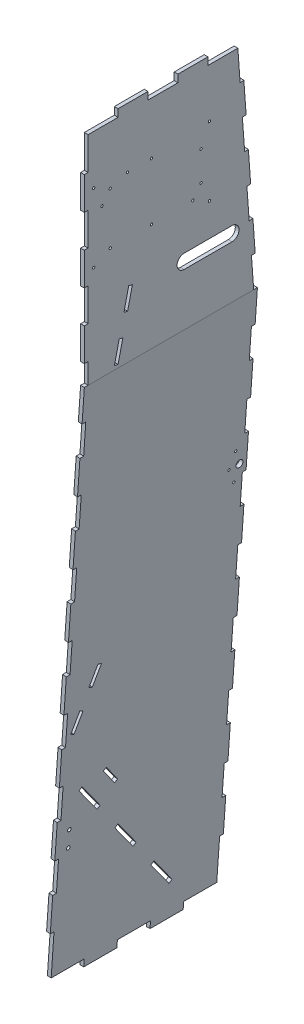
from build123d import *

# Parameters (mm, degrees)
BOSS_EXTRUDE1_DEPTH = 469.9
SKETCH2_W           = 10.16
SKETCH2_H           = 83.810703233
SKETCH2_H_2         = 111.159792755
SKETCH2_H_3         = 83.757510526
SKETCH2_H_4         = 83.784106879
SKETCH2_H_5         = 83.730914172
SKETCH2_H_6         = 83.704317819
SKETCH2_H_7         = 83.677721465
SKETCH2_H_8         = 83.651125112
SKETCH2_H_9         = 22.104476438
CUT_EXTRUDE1_DEPTH  = 10.16
SKETCH3_W           = 10.16
SKETCH3_H           = 55.879999965
SKETCH3_H_2         = 88.9
SKETCH3_H_3         = 109.22
CUT_EXTRUDE2_DEPTH  = 12.7
SKETCH4_W           = 81.316938584
SKETCH4_H           = 20.32
SKETCH4_W_2         = 81.316938585
CUT_EXTRUDE3_DEPTH  = 12.7
SKETCH5_W           = 89.916
SKETCH5_H           = 20.32
CUT_EXTRUDE4_DEPTH  = 12.7
CUT_EXTRUDE5_DEPTH  = 137.414
SKETCH8_R           = 9.525
CUT_EXTRUDE7_DEPTH  = 102.618210735
SKETCH13_R          = 3.175
CUT_EXTRUDE8_DEPTH  = 11.166490401
CUT_EXTRUDE9_DEPTH  = 11.166490401
SKETCH20_R          = 4.7625
CUT_EXTRUDE10_DEPTH = 112.516033618
SKETCH23_R          = 3.175
CUT_EXTRUDE11_DEPTH = 112.516033618


with BuildPart() as part:
    # Sketch1 → Boss-Extrude1 (new body)
    with BuildSketch(Plane.XY):
        Polygon((-215.881789204, 2052.32), (-215.881789204, 1463.040000035), (-316.088635901, 20.32), (-317.499999939, 0), (-307.333509538, 0), (-205.715298803, 1463.040000035), (-205.715298803, 2072.64), (-215.881789204, 2072.64), align=None)
    extrude(amount=-BOSS_EXTRUDE1_DEPTH)

    # Sketch2 → Cut-Extrude1 (cut)
    with BuildSketch(Plane(origin=(-315.975651309, 21.946686571, 0), x_dir=(0, 0, 1), z_dir=(-0.997596563, 0.069289956, 0))):
        with Locations((-5.08, 247.132760087)):
            Rectangle(SKETCH2_W, SKETCH2_H)
        with Locations((-5.08, 55.684811679)):
            Rectangle(SKETCH2_W, SKETCH2_H_2)
        with Locations((-5.08, 602.706163733)):
            Rectangle(SKETCH2_W, SKETCH2_H_3)
        with Locations((-5.08, 424.91946191)):
            Rectangle(SKETCH2_W, SKETCH2_H_4)
        with Locations((-5.08, 780.492865556)):
            Rectangle(SKETCH2_W, SKETCH2_H_5)
        with Locations((-5.08, 958.27956738)):
            Rectangle(SKETCH2_W, SKETCH2_H_6)
        with Locations((-5.08, 1136.066269203)):
            Rectangle(SKETCH2_W, SKETCH2_H_7)
        with Locations((-5.08, 1313.852971026)):
            Rectangle(SKETCH2_W, SKETCH2_H_8)
        with Locations((-5.08, -10.947322918)):
            Rectangle(SKETCH2_W, SKETCH2_H_9)
        with Locations((-464.82, -10.947322918)):
            Rectangle(SKETCH2_W, SKETCH2_H_9)
        with Locations((-464.82, 55.684811679)):
            Rectangle(SKETCH2_W, SKETCH2_H_2)
        with Locations((-464.82, 247.132760087)):
            Rectangle(SKETCH2_W, SKETCH2_H)
        with Locations((-464.82, 424.91946191)):
            Rectangle(SKETCH2_W, SKETCH2_H_4)
        with Locations((-464.82, 602.706163733)):
            Rectangle(SKETCH2_W, SKETCH2_H_3)
        with Locations((-464.82, 780.492865556)):
            Rectangle(SKETCH2_W, SKETCH2_H_5)
        with Locations((-464.82, 958.27956738)):
            Rectangle(SKETCH2_W, SKETCH2_H_6)
        with Locations((-464.82, 1136.066269203)):
            Rectangle(SKETCH2_W, SKETCH2_H_7)
        with Locations((-464.82, 1313.852971026)):
            Rectangle(SKETCH2_W, SKETCH2_H_8)
    extrude(amount=-CUT_EXTRUDE1_DEPTH, mode=Mode.SUBTRACT)

    # Sketch3 → Cut-Extrude2 (cut)
    with BuildSketch(Plane.ZY.offset(215.881789204)):
        with Locations((-5.08, 1490.980000018)):
            Rectangle(SKETCH3_W, SKETCH3_H)
        with Locations((-5.08, 1652.27)):
            Rectangle(SKETCH3_W, SKETCH3_H_2)
        Polygon((-469.9, 1463.040000035), (-459.713026258, 1463.040000035), (-453.620872406, 1546.589538567), (-463.753970086, 1547.328410273), (-457.607940173, 1631.616820512), (-447.474842492, 1630.877948806), (-441.328812579, 1715.166359045), (-451.461910259, 1715.905230751), (-445.315880346, 1800.19364099), (-435.182782665, 1799.454769284), (-429.036752752, 1883.743179522), (-439.169850432, 1884.482051228), (-433.023820518, 1968.770461467), (-422.890722838, 1968.031589761), (-415.263026258, 2072.64), (-469.9, 2072.64), align=None)
        with Locations((-5.08, 1830.07)):
            Rectangle(SKETCH3_W, SKETCH3_H_2)
        with Locations((-5.08, 2018.03)):
            Rectangle(SKETCH3_W, SKETCH3_H_3)
    extrude(amount=-CUT_EXTRUDE2_DEPTH, mode=Mode.SUBTRACT)

    # Sketch4 → Cut-Extrude3 (cut)
    with BuildSketch(Plane.ZY.offset(215.881789204)):
        with Locations((-376.086223632, 2062.48)):
            Rectangle(SKETCH4_W, SKETCH4_H)
        with Locations((-213.452346463, 2062.48)):
            Rectangle(SKETCH4_W_2, SKETCH4_H)
        with Locations((-50.818469292, 2062.48)):
            Rectangle(SKETCH4_W_2, SKETCH4_H)
    extrude(amount=-CUT_EXTRUDE3_DEPTH, mode=Mode.SUBTRACT)

    # Sketch5 → Cut-Extrude4 (cut)
    with BuildSketch(Plane(origin=(-315.975651309, 21.946686571, 0), x_dir=(0, 0, 1), z_dir=(-0.997596563, 0.069289956, 0))):
        with Locations((-414.782, -11.839561137)):
            Rectangle(SKETCH5_W, SKETCH5_H)
        with Locations((-234.95, -11.839561137)):
            Rectangle(SKETCH5_W, SKETCH5_H)
        with Locations((-55.118, -11.839561137)):
            Rectangle(SKETCH5_W, SKETCH5_H)
    extrude(amount=-CUT_EXTRUDE4_DEPTH, mode=Mode.SUBTRACT)

    # Sketch6 → Cut-Extrude5 (cut)
    with BuildSketch(Plane(origin=(-315.975651309, 21.946686571, 0), x_dir=(0, 0, 1), z_dir=(-0.997596563, 0.069289956, 0))):
        Polygon((-87.26775037, 725.157981502), (-65.68812669, 678.917255627), (-74.89887104, 674.61878511), (-96.478494721, 720.859510985), align=None)
        Polygon((-53.31924736, 628.378059234), (-44.10850301, 632.676529752), (-22.52887933, 586.435803877), (-31.73962368, 582.137333359), align=None)
        Polygon((-117.688081031, 364.457321541), (-109.500847052, 358.426570287), (-55.568463259, 431.644155721), (-63.755697238, 437.674906975), align=None)
        Polygon((-225.552848619, 218.022150673), (-217.372552167, 211.996509631), (-163.440168374, 285.214095065), (-171.620464825, 291.239736107), align=None)
        Polygon((-333.417616206, 71.586979805), (-325.230382227, 65.556228551), (-271.297998434, 138.773813985), (-279.485232413, 144.804565239), align=None)
    extrude(amount=-CUT_EXTRUDE5_DEPTH, mode=Mode.SUBTRACT)

    # Sketch8 → Cut-Extrude7 (cut, through all)
    with BuildSketch(Plane.ZY.offset(215.881789204)):
        with Locations((-450.215, 1043.94)):
            Circle(SKETCH8_R)
    extrude(amount=CUT_EXTRUDE7_DEPTH, mode=Mode.SUBTRACT)

    # Sketch13 → Cut-Extrude8 (cut, through all)
    with BuildSketch(Plane.ZY.offset(215.881789204)):
        with BuildLine():
            Line((-400.855976046, 1605.059439633), (-270.871476046, 1605.059439633))
            ThreePointArc((-270.871476046, 1605.059439633), (-251.821476046, 1624.109439633), (-270.871476046, 1643.159439633))
            Line((-270.871476046, 1643.159439633), (-400.855976046, 1643.159439633))
            ThreePointArc((-400.855976046, 1643.159439633), (-419.905976046, 1624.109439633), (-400.855976046, 1605.059439633))
        make_face()
        with Locations((-25.246459893, 1731.87)):
            Circle(SKETCH13_R)
        with Locations((-70.408959893, 1755.42)):
            Circle(SKETCH13_R)
        with Locations((-182.408959893, 1755.42)):
            Circle(SKETCH13_R)
        with Locations((-25.246459893, 1918.97)):
            Circle(SKETCH13_R)
        with Locations((-47.788959893, 1865.42)):
            Circle(SKETCH13_R)
        with Locations((-182.408959893, 1910.42)):
            Circle(SKETCH13_R)
        with Locations((-117.078959893, 1910.42)):
            Circle(SKETCH13_R)
        with Locations((-70.408959893, 1895.42)):
            Circle(SKETCH13_R)
        with Locations((-317.028959893, 1865.42)):
            Circle(SKETCH13_R)
        with Locations((-294.408959893, 1755.42)):
            Circle(SKETCH13_R)
        with Locations((-317.028959893, 1785.42)):
            Circle(SKETCH13_R)
        with Locations((-339.571459893, 1731.87)):
            Circle(SKETCH13_R)
        with Locations((-339.571459893, 1918.97)):
            Circle(SKETCH13_R)
    extrude(amount=-CUT_EXTRUDE8_DEPTH, mode=Mode.SUBTRACT)

    # Sketch17 → Cut-Extrude9 (cut, through all)
    with BuildSketch(Plane.ZY.offset(215.881789204)):
        Polygon((-91.602336227, 1471.504269383), (-81.702736369, 1473.789772095), (-94.643375784, 1529.841839519), (-104.542975642, 1527.556336807), align=None)
        Polygon((-130.424254473, 1639.660471655), (-117.483615058, 1583.608404231), (-107.584015199, 1585.893906943), (-120.524654614, 1641.945974367), align=None)
    extrude(amount=-CUT_EXTRUDE9_DEPTH, mode=Mode.SUBTRACT)

    # Sketch20 → Cut-Extrude10 (cut, through all)
    with BuildSketch(Plane(origin=(-315.975651309, 21.946686571, 0), x_dir=(0, 0, 1), z_dir=(-0.997596563, 0.069289956, 0))):
        with Locations((-35.56, 347.287639338)):
            Circle(SKETCH20_R)
        with Locations((-35.56, 302.837639338)):
            Circle(SKETCH20_R)
        Polygon((-120.929306778, 445.712379572), (-154.823537638, 399.698212032), (-162.492565561, 405.347250509), (-128.598334701, 451.361418049), align=None)
    extrude(amount=-CUT_EXTRUDE10_DEPTH, mode=Mode.SUBTRACT)

    # Sketch23 → Cut-Extrude11 (cut, through all)
    with BuildSketch(Plane(origin=(-315.975651309, 21.946686571, 0), x_dir=(0, 0, 1), z_dir=(-0.997596563, 0.069289956, 0))):
        with Locations((-421.64, 1024.455528037)):
            Circle(SKETCH23_R)
        with Locations((-437.515, 986.355528037)):
            Circle(SKETCH23_R)
        with Locations((-437.515, 1062.555528037)):
            Circle(SKETCH23_R)
    extrude(amount=-CUT_EXTRUDE11_DEPTH, mode=Mode.SUBTRACT)


solid = part.part
